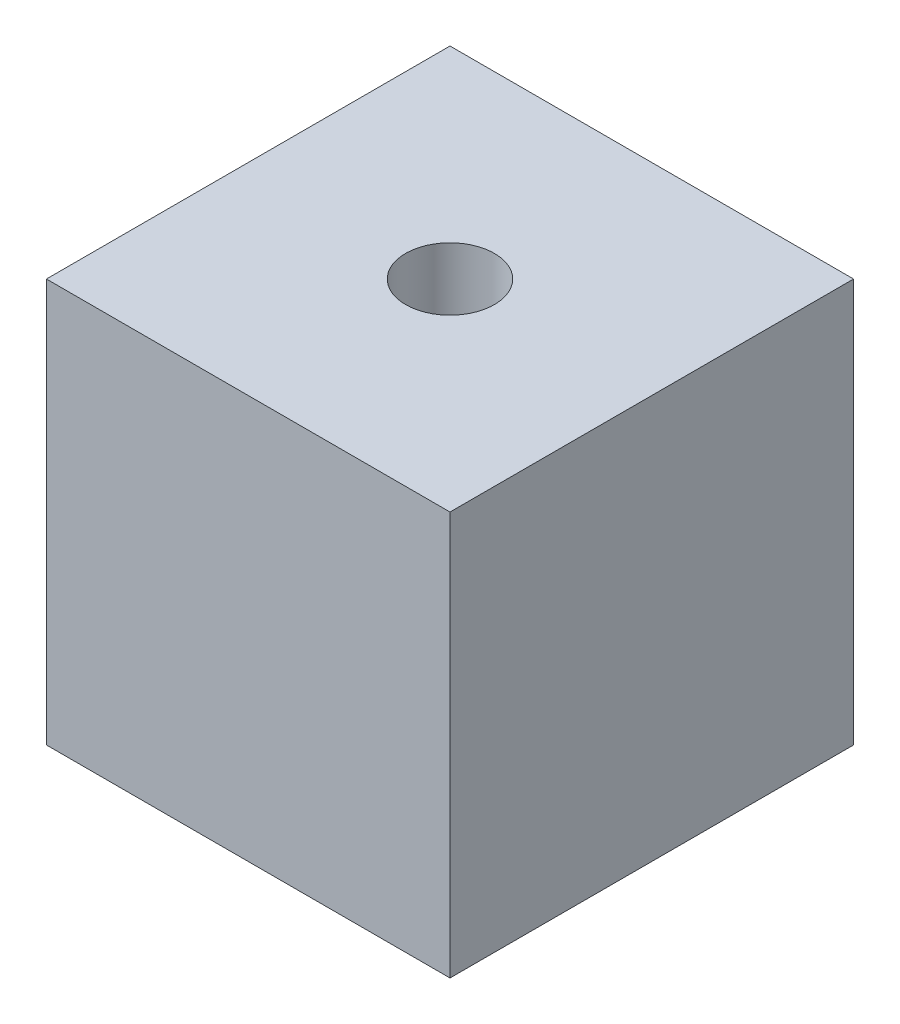
from build123d import *

# Parameters (mm, degrees)
SKETCH1_W                = 10
SKETCH1_H                = 10
BOSS_EXTRUDE1_DEPTH      = 10
M2_CLEARANCE_HOLE1_D     = 2.2
M2_CLEARANCE_HOLE1_DEPTH = 7.339053319
M2_CLEARANCE_HOLE1_TIP   = 0.660946681


with BuildPart() as part:
    # Sketch1 → Boss-Extrude1 (new body)
    with BuildSketch(Plane(origin=(0, 0, 0), x_dir=(1, 0, 0), z_dir=(0, 1, 0))):
        with Locations((5, 5)):
            Rectangle(SKETCH1_W, SKETCH1_H)
    extrude(amount=BOSS_EXTRUDE1_DEPTH)

    # M2 Clearance Hole1
    with Locations(Plane(origin=(0, 10, 0), x_dir=(1, 0, 0), z_dir=(0, 1, 0))):
        with Locations((5, 5)):
            Hole(M2_CLEARANCE_HOLE1_D / 2, depth=M2_CLEARANCE_HOLE1_DEPTH)
            with Locations((0, 0, -(M2_CLEARANCE_HOLE1_DEPTH + M2_CLEARANCE_HOLE1_TIP / 2))):  # 118° drill point
                Cone(0, M2_CLEARANCE_HOLE1_D / 2, M2_CLEARANCE_HOLE1_TIP, mode=Mode.SUBTRACT)


solid = part.part
